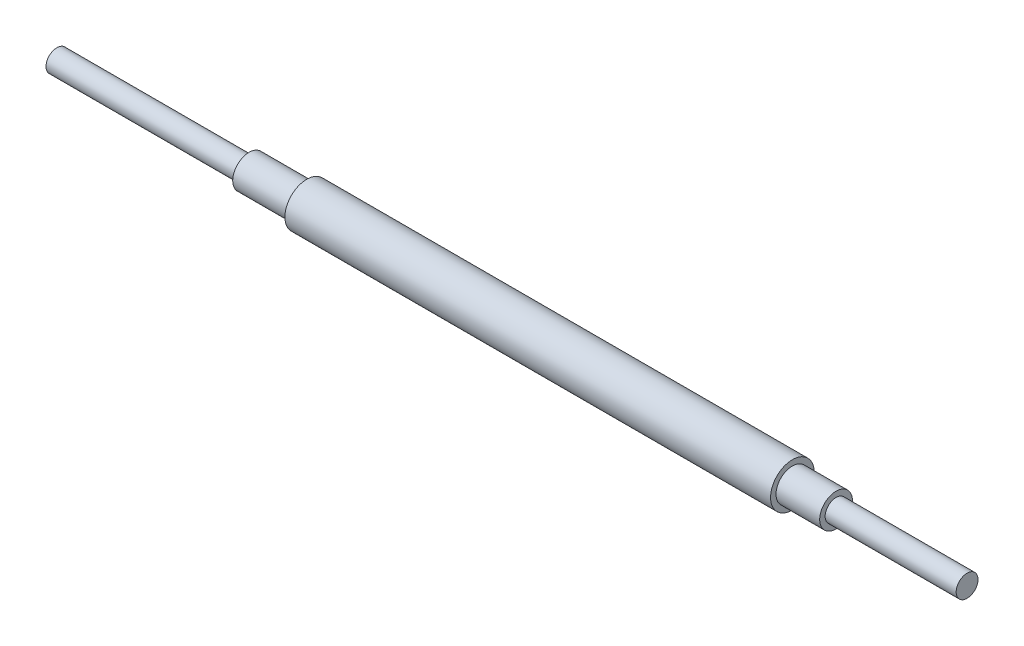
from build123d import *


with BuildPart() as part:
    # Sketch1 → Revolve1 (revolve)
    with BuildSketch(Plane.XY):
        Polygon((0.612446545, 3.175), (0.612446545, 0), (-264.055553455, 0), (-264.055553455, 3.175), (-208.175553455, 3.175), (-208.175553455, 4.7625), (-191.411553455, 4.7625), (-191.411553455, 6.35), (-50.187553455, 6.35), (-50.187553455, 4.7625), (-37.487553455, 4.7625), (-37.487553455, 3.175), align=None)
    revolve(axis=Axis((-264.055553455, 0, 0), (1, 0, 0)))


solid = part.part
